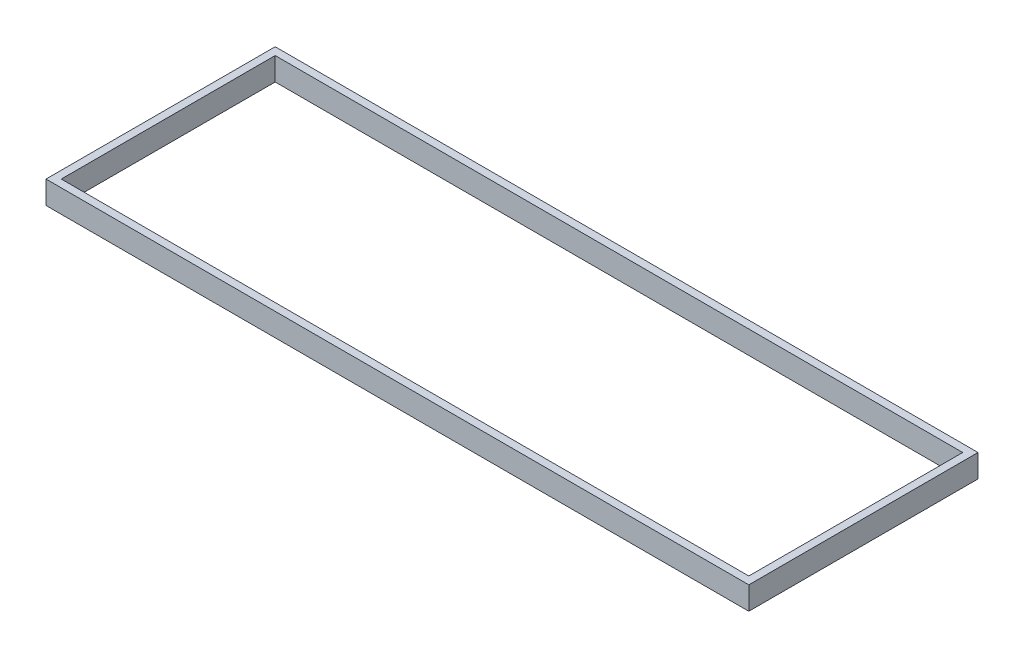
from build123d import *

# Parameters (mm, degrees)
SKETCH1_W           = 92
SKETCH1_H           = 30
SKETCH1_W_2         = 90
SKETCH1_H_2         = 28
EXTRUDE_THIN1_DEPTH = 3


with BuildPart() as part:
    # Sketch1 → Extrude-Thin1 (new body)
    with BuildSketch(Plane(origin=(0, 0, 0), x_dir=(1, 0, 0), z_dir=(0, 1, 0))):
        Rectangle(SKETCH1_W, SKETCH1_H)
        Rectangle(SKETCH1_W_2, SKETCH1_H_2, mode=Mode.SUBTRACT)
    extrude(amount=EXTRUDE_THIN1_DEPTH)


solid = part.part
